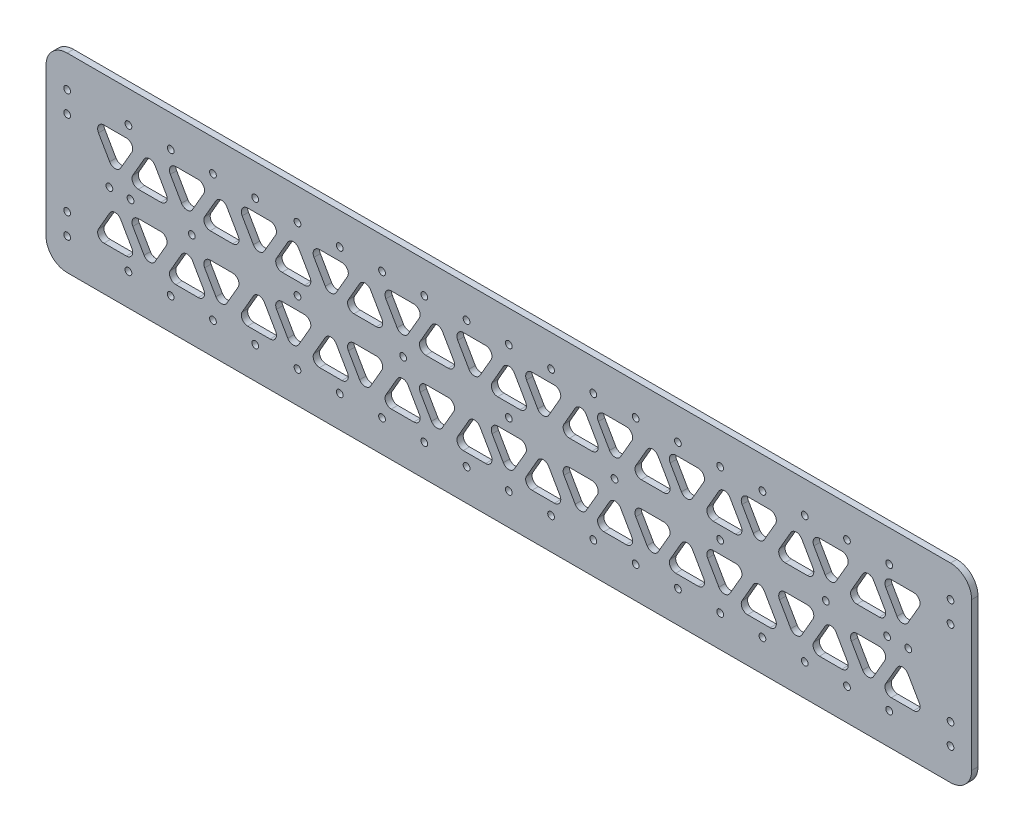
from build123d import *

# Parameters (mm, degrees)
SKETCH_1_W          = 438
SKETCH_1_H          = 90
SKETCH_1_R          = 1.6
EXTRUDE_1_DEPTH     = 3
SKETCH_2_R          = 1.6
CUT_EXTRUDE_1_DEPTH = 10
SKETCH_3_R          = 1.6
CUT_EXTRUDE_2_DEPTH = 10
FILLET_1_R          = 10
CUT_EXTRUDE_3_DEPTH = 10
FILLET_2_R          = 3


with BuildPart() as part:
    # 草图1 → 凸台-拉伸1 (new body)
    with BuildSketch(Plane.XY):
        Rectangle(SKETCH_1_W, SKETCH_1_H)
        Circle(SKETCH_1_R, mode=Mode.SUBTRACT)
        with Locations((50, 0)):
            Circle(SKETCH_1_R, mode=Mode.SUBTRACT)
        with Locations((100, 0)):
            Circle(SKETCH_1_R, mode=Mode.SUBTRACT)
        with Locations((150, 0)):
            Circle(SKETCH_1_R, mode=Mode.SUBTRACT)
        with Locations((-50, 0)):
            Circle(SKETCH_1_R, mode=Mode.SUBTRACT)
        with Locations((-100, 0)):
            Circle(SKETCH_1_R, mode=Mode.SUBTRACT)
        with Locations((-150, 0)):
            Circle(SKETCH_1_R, mode=Mode.SUBTRACT)
    extrude(amount=EXTRUDE_1_DEPTH)

    # 草图2 → 切除-拉伸1 (cut)
    with BuildSketch(Plane.XY.offset(3)):
        with Locations((179, 0)):
            Circle(SKETCH_2_R)
        with Locations((189, 0)):
            Circle(SKETCH_2_R)
        with Locations((-189, 0)):
            Circle(SKETCH_2_R)
        with Locations((-179, 0)):
            Circle(SKETCH_2_R)
        with Locations((209, -20)):
            Circle(SKETCH_2_R)
        with Locations((209, -30)):
            Circle(SKETCH_2_R)
        with Locations((209, 30)):
            Circle(SKETCH_2_R)
        with Locations((209, 20)):
            Circle(SKETCH_2_R)
        with Locations((-209, 20)):
            Circle(SKETCH_2_R)
        with Locations((-209, 30)):
            Circle(SKETCH_2_R)
        with Locations((-209, -30)):
            Circle(SKETCH_2_R)
        with Locations((-209, -20)):
            Circle(SKETCH_2_R)
    extrude(amount=-CUT_EXTRUDE_1_DEPTH, mode=Mode.SUBTRACT)

    # 草图3 → 切除-拉伸2 (cut)
    with BuildSketch(Plane.XY.offset(3)):
        with Locations((0, -30)):
            Circle(SKETCH_3_R)
        with Locations((20, -30)):
            Circle(SKETCH_3_R)
        with Locations((40, -30)):
            Circle(SKETCH_3_R)
        with Locations((60, -30)):
            Circle(SKETCH_3_R)
        with Locations((80, -30)):
            Circle(SKETCH_3_R)
        with Locations((100, -30)):
            Circle(SKETCH_3_R)
        with Locations((120, -30)):
            Circle(SKETCH_3_R)
        with Locations((140, -30)):
            Circle(SKETCH_3_R)
        with Locations((160, -30)):
            Circle(SKETCH_3_R)
        with Locations((180, -30)):
            Circle(SKETCH_3_R)
        with Locations((-20, -30)):
            Circle(SKETCH_3_R)
        with Locations((-40, -30)):
            Circle(SKETCH_3_R)
        with Locations((-60, -30)):
            Circle(SKETCH_3_R)
        with Locations((-80, -30)):
            Circle(SKETCH_3_R)
        with Locations((-100, -30)):
            Circle(SKETCH_3_R)
        with Locations((-120, -30)):
            Circle(SKETCH_3_R)
        with Locations((-140, -30)):
            Circle(SKETCH_3_R)
        with Locations((-160, -30)):
            Circle(SKETCH_3_R)
        with Locations((-180, -30)):
            Circle(SKETCH_3_R)
        with Locations((-180, 30)):
            Circle(SKETCH_3_R)
        with Locations((-160, 30)):
            Circle(SKETCH_3_R)
        with Locations((-140, 30)):
            Circle(SKETCH_3_R)
        with Locations((-120, 30)):
            Circle(SKETCH_3_R)
        with Locations((-100, 30)):
            Circle(SKETCH_3_R)
        with Locations((-80, 30)):
            Circle(SKETCH_3_R)
        with Locations((-60, 30)):
            Circle(SKETCH_3_R)
        with Locations((-40, 30)):
            Circle(SKETCH_3_R)
        with Locations((-20, 30)):
            Circle(SKETCH_3_R)
        with Locations((180, 30)):
            Circle(SKETCH_3_R)
        with Locations((160, 30)):
            Circle(SKETCH_3_R)
        with Locations((140, 30)):
            Circle(SKETCH_3_R)
        with Locations((120, 30)):
            Circle(SKETCH_3_R)
        with Locations((100, 30)):
            Circle(SKETCH_3_R)
        with Locations((80, 30)):
            Circle(SKETCH_3_R)
        with Locations((60, 30)):
            Circle(SKETCH_3_R)
        with Locations((40, 30)):
            Circle(SKETCH_3_R)
        with Locations((20, 30)):
            Circle(SKETCH_3_R)
        with Locations((0, 30)):
            Circle(SKETCH_3_R)
    extrude(amount=-CUT_EXTRUDE_2_DEPTH, mode=Mode.SUBTRACT)

    # 圆角1
    fillet_1_edges = [part.edges().sort_by_distance(p)[0] for p in [
        (219, -45, 1.5),
        (-219, -45, 1.5),
        (-219, 45, 1.5),
        (219, 45, 1.5),
    ]]
    fillet(fillet_1_edges, radius=FILLET_1_R)

    # 草图4 → 切除-拉伸3 (cut)
    with BuildSketch(Plane.XY.offset(3)):
        Polygon((-10.5, 6), (10.5, 6), (0, 24.186533479), align=None)
        Polygon((5.773502692, 24.186533479), (16.273502692, 6), (26.773502692, 24.186533479), align=None)
        Polygon((60.773502692, 24.186533479), (39.773502692, 24.186533479), (50.273502692, 6), align=None)
        Polygon((34, 24.186533479), (23.5, 6), (44.5, 6), align=None)
        Polygon((94.773502692, 24.186533479), (73.773502692, 24.186533479), (84.273502692, 6), align=None)
        Polygon((68, 24.186533479), (57.5, 6), (78.5, 6), align=None)
        Polygon((128.773502692, 24.186533479), (107.773502692, 24.186533479), (118.273502692, 6), align=None)
        Polygon((102, 24.186533479), (91.5, 6), (112.5, 6), align=None)
        Polygon((162.773502692, 24.186533479), (141.773502692, 24.186533479), (152.273502692, 6), align=None)
        Polygon((136, 24.186533479), (125.5, 6), (146.5, 6), align=None)
        Polygon((196.773502692, 24.186533479), (175.773502692, 24.186533479), (186.273502692, 6), align=None)
        Polygon((170, 24.186533479), (159.5, 6), (180.5, 6), align=None)
        Polygon((-180.5, 6), (-170, 24.186533479), (-159.5, 6), align=None)
        Polygon((-186.273502692, 6), (-196.773502692, 24.186533479), (-175.773502692, 24.186533479), align=None)
        Polygon((-146.5, 6), (-136, 24.186533479), (-125.5, 6), align=None)
        Polygon((-152.273502692, 6), (-162.773502692, 24.186533479), (-141.773502692, 24.186533479), align=None)
        Polygon((-112.5, 6), (-102, 24.186533479), (-91.5, 6), align=None)
        Polygon((-118.273502692, 6), (-128.773502692, 24.186533479), (-107.773502692, 24.186533479), align=None)
        Polygon((-78.5, 6), (-68, 24.186533479), (-57.5, 6), align=None)
        Polygon((-84.273502692, 6), (-94.773502692, 24.186533479), (-73.773502692, 24.186533479), align=None)
        Polygon((-44.5, 6), (-34, 24.186533479), (-23.5, 6), align=None)
        Polygon((-50.273502692, 6), (-60.773502692, 24.186533479), (-39.773502692, 24.186533479), align=None)
        Polygon((-26.773502692, 24.186533479), (-5.773502692, 24.186533479), (-16.273502692, 6), align=None)
        Polygon((-10.5, -6), (0, -24.186533479), (10.5, -6), align=None)
        Polygon((-5.773502692, -24.186533479), (-16.273502692, -6), (-26.773502692, -24.186533479), align=None)
        Polygon((-60.773502692, -24.186533479), (-39.773502692, -24.186533479), (-50.273502692, -6), align=None)
        Polygon((-34, -24.186533479), (-23.5, -6), (-44.5, -6), align=None)
        Polygon((-94.773502692, -24.186533479), (-73.773502692, -24.186533479), (-84.273502692, -6), align=None)
        Polygon((-68, -24.186533479), (-57.5, -6), (-78.5, -6), align=None)
        Polygon((-128.773502692, -24.186533479), (-107.773502692, -24.186533479), (-118.273502692, -6), align=None)
        Polygon((-102, -24.186533479), (-91.5, -6), (-112.5, -6), align=None)
        Polygon((-162.773502692, -24.186533479), (-141.773502692, -24.186533479), (-152.273502692, -6), align=None)
        Polygon((-136, -24.186533479), (-125.5, -6), (-146.5, -6), align=None)
        Polygon((-196.773502692, -24.186533479), (-175.773502692, -24.186533479), (-186.273502692, -6), align=None)
        Polygon((-170, -24.186533479), (-159.5, -6), (-180.5, -6), align=None)
        Polygon((180.5, -6), (170, -24.186533479), (159.5, -6), align=None)
        Polygon((186.273502692, -6), (196.773502692, -24.186533479), (175.773502692, -24.186533479), align=None)
        Polygon((146.5, -6), (136, -24.186533479), (125.5, -6), align=None)
        Polygon((152.273502692, -6), (162.773502692, -24.186533479), (141.773502692, -24.186533479), align=None)
        Polygon((112.5, -6), (102, -24.186533479), (91.5, -6), align=None)
        Polygon((118.273502692, -6), (128.773502692, -24.186533479), (107.773502692, -24.186533479), align=None)
        Polygon((78.5, -6), (68, -24.186533479), (57.5, -6), align=None)
        Polygon((84.273502692, -6), (94.773502692, -24.186533479), (73.773502692, -24.186533479), align=None)
        Polygon((44.5, -6), (34, -24.186533479), (23.5, -6), align=None)
        Polygon((50.273502692, -6), (60.773502692, -24.186533479), (39.773502692, -24.186533479), align=None)
        Polygon((26.773502692, -24.186533479), (5.773502692, -24.186533479), (16.273502692, -6), align=None)
    extrude(amount=-CUT_EXTRUDE_3_DEPTH, mode=Mode.SUBTRACT)

    # 圆角2
    fillet_2_edges = [part.edges().sort_by_distance(p)[0] for p in [
        (-10.5, -6, 1.5),
        (10.5, -6, 1.5),
        (0, -24.186533479, 1.5),
        (-5.773502692, -24.186533479, 1.5),
        (-26.773502692, -24.186533479, 1.5),
        (-16.273502692, -6, 1.5),
        (-16.273502692, 6, 1.5),
        (-26.773502692, 24.186533479, 1.5),
        (-5.773502692, 24.186533479, 1.5),
        (-39.773502692, 24.186533479, 1.5),
        (-50.273502692, 6, 1.5),
        (-60.773502692, 24.186533479, 1.5),
        (-107.773502692, 24.186533479, 1.5),
        (-118.273502692, 6, 1.5),
        (-128.773502692, 24.186533479, 1.5),
        (-57.5, 6, 1.5),
        (-78.5, 6, 1.5),
        (-68, 24.186533479, 1.5),
        (-73.773502692, 24.186533479, 1.5),
        (-84.273502692, 6, 1.5),
        (-94.773502692, 24.186533479, 1.5),
        (-23.5, 6, 1.5),
        (-44.5, 6, 1.5),
        (-34, 24.186533479, 1.5),
        (-102, -24.186533479, 1.5),
        (-112.5, -6, 1.5),
        (-91.5, -6, 1.5),
        (-128.773502692, -24.186533479, 1.5),
        (-118.273502692, -6, 1.5),
        (-107.773502692, -24.186533479, 1.5),
        (-136, -24.186533479, 1.5),
        (-146.5, -6, 1.5),
        (-125.5, -6, 1.5),
        (-162.773502692, -24.186533479, 1.5),
        (-152.273502692, -6, 1.5),
        (-141.773502692, -24.186533479, 1.5),
        (-34, -24.186533479, 1.5),
        (-44.5, -6, 1.5),
        (-23.5, -6, 1.5),
        (-60.773502692, -24.186533479, 1.5),
        (-50.273502692, -6, 1.5),
        (-39.773502692, -24.186533479, 1.5),
        (-68, -24.186533479, 1.5),
        (-78.5, -6, 1.5),
        (-57.5, -6, 1.5),
        (-94.773502692, -24.186533479, 1.5),
        (-84.273502692, -6, 1.5),
        (-73.773502692, -24.186533479, 1.5),
        (68, 24.186533479, 1.5),
        (78.5, 6, 1.5),
        (57.5, 6, 1.5),
        (94.773502692, 24.186533479, 1.5),
        (84.273502692, 6, 1.5),
        (73.773502692, 24.186533479, 1.5),
        (102, 24.186533479, 1.5),
        (112.5, 6, 1.5),
        (91.5, 6, 1.5),
        (128.773502692, 24.186533479, 1.5),
        (118.273502692, 6, 1.5),
        (107.773502692, 24.186533479, 1.5),
        (60.773502692, 24.186533479, 1.5),
        (50.273502692, 6, 1.5),
        (39.773502692, 24.186533479, 1.5),
        (34, 24.186533479, 1.5),
        (44.5, 6, 1.5),
        (23.5, 6, 1.5),
        (-159.5, 6, 1.5),
        (-180.5, 6, 1.5),
        (-170, 24.186533479, 1.5),
        (0, 24.186533479, 1.5),
        (10.5, 6, 1.5),
        (-10.5, 6, 1.5),
        (196.773502692, 24.186533479, 1.5),
        (186.273502692, 6, 1.5),
        (175.773502692, 24.186533479, 1.5),
        (170, 24.186533479, 1.5),
        (180.5, 6, 1.5),
        (159.5, 6, 1.5),
        (162.773502692, 24.186533479, 1.5),
        (152.273502692, 6, 1.5),
        (141.773502692, 24.186533479, 1.5),
        (136, 24.186533479, 1.5),
        (146.5, 6, 1.5),
        (125.5, 6, 1.5),
        (-91.5, 6, 1.5),
        (-112.5, 6, 1.5),
        (-102, 24.186533479, 1.5),
        (-141.773502692, 24.186533479, 1.5),
        (-152.273502692, 6, 1.5),
        (-162.773502692, 24.186533479, 1.5),
        (-125.5, 6, 1.5),
        (-146.5, 6, 1.5),
        (-136, 24.186533479, 1.5),
        (-175.773502692, 24.186533479, 1.5),
        (-186.273502692, 6, 1.5),
        (-196.773502692, 24.186533479, 1.5),
        (23.5, -6, 1.5),
        (44.5, -6, 1.5),
        (34, -24.186533479, 1.5),
        (39.773502692, -24.186533479, 1.5),
        (50.273502692, -6, 1.5),
        (60.773502692, -24.186533479, 1.5),
        (57.5, -6, 1.5),
        (78.5, -6, 1.5),
        (68, -24.186533479, 1.5),
        (73.773502692, -24.186533479, 1.5),
        (84.273502692, -6, 1.5),
        (94.773502692, -24.186533479, 1.5),
        (16.273502692, -6, 1.5),
        (26.773502692, -24.186533479, 1.5),
        (5.773502692, -24.186533479, 1.5),
        (-170, -24.186533479, 1.5),
        (-180.5, -6, 1.5),
        (-159.5, -6, 1.5),
        (-196.773502692, -24.186533479, 1.5),
        (-186.273502692, -6, 1.5),
        (-175.773502692, -24.186533479, 1.5),
        (175.773502692, -24.186533479, 1.5),
        (186.273502692, -6, 1.5),
        (196.773502692, -24.186533479, 1.5),
        (159.5, -6, 1.5),
        (180.5, -6, 1.5),
        (170, -24.186533479, 1.5),
        (91.5, -6, 1.5),
        (112.5, -6, 1.5),
        (102, -24.186533479, 1.5),
        (107.773502692, -24.186533479, 1.5),
        (118.273502692, -6, 1.5),
        (128.773502692, -24.186533479, 1.5),
        (125.5, -6, 1.5),
        (146.5, -6, 1.5),
        (136, -24.186533479, 1.5),
        (141.773502692, -24.186533479, 1.5),
        (152.273502692, -6, 1.5),
        (162.773502692, -24.186533479, 1.5),
        (5.773502692, 24.186533479, 1.5),
        (26.773502692, 24.186533479, 1.5),
        (16.273502692, 6, 1.5),
    ]]
    fillet(fillet_2_edges, radius=FILLET_2_R)


solid = part.part
